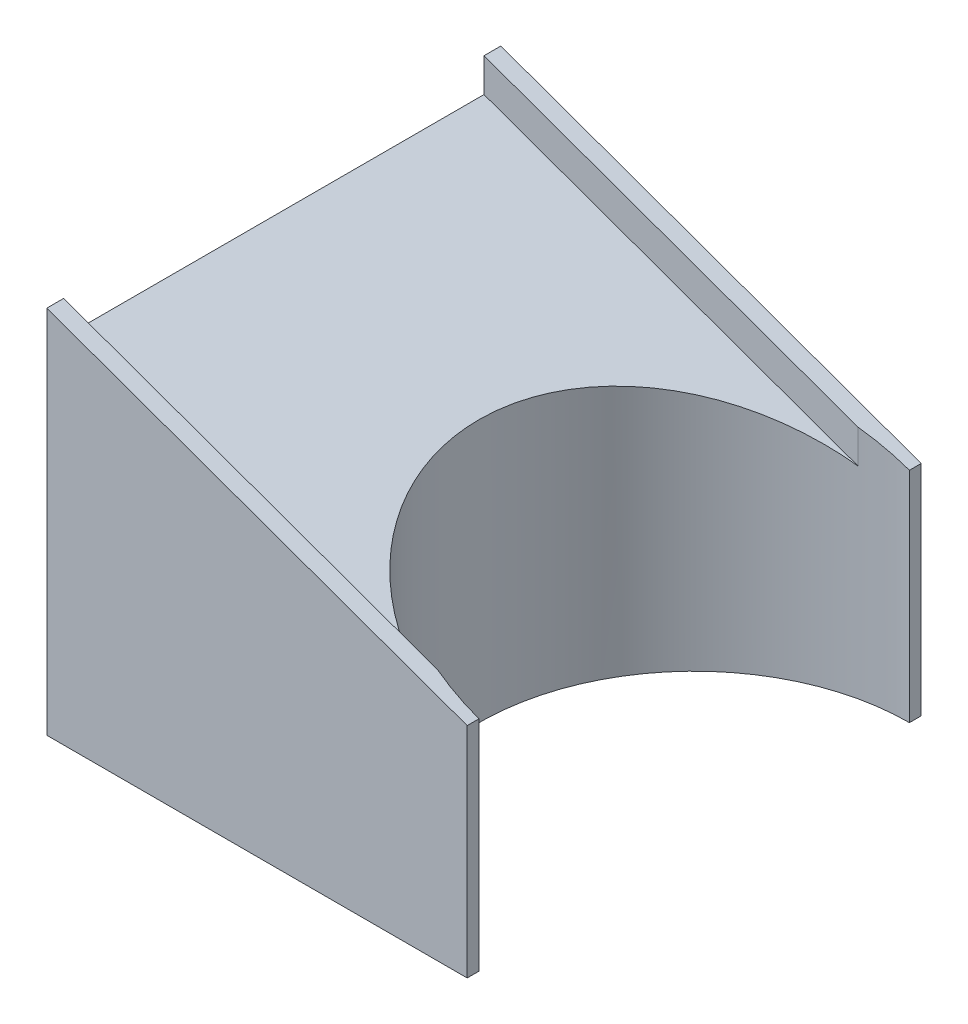
from build123d import *

# Parameters (mm, degrees)
BOSS_EXTRUDE1_DEPTH        = 62.5
BOSS_EXTRUDE2_DEPTH        = 5
SKETCH3_R                  = 64
CUT_EXTRUDE1_DEPTH         = 111
F_10_CLEARANCE_HOLE1_D     = 4.7752
F_10_CLEARANCE_HOLE1_DEPTH = 12.7
F_10_CLEARANCE_HOLE1_TIP   = 1.434614814


with BuildPart() as part:
    # Sketch2 → Boss-Extrude1 (new body, symmetric)
    with BuildSketch(Plane.XY):
        Polygon((0, 0), (0, 100), (125, 55), (125, 0), align=None)
    extrude(amount=BOSS_EXTRUDE1_DEPTH, both=True)

    # Sketch4 → Boss-Extrude2 (add)
    with BuildSketch(Plane.XY.offset(62.5)):
        Polygon((0, 0), (0, 110), (125, 65), (125, 0), align=None)
    boss_extrude2 = extrude(amount=BOSS_EXTRUDE2_DEPTH)

    # Mirror1: Boss-Extrude2 across plane
    add(boss_extrude2.mirror(Plane.XY))

    # Sketch3 → Cut-Extrude1 (cut, through all)
    with BuildSketch(Plane.XZ):
        with Locations((125, 0)):
            Circle(SKETCH3_R)
    extrude(amount=-CUT_EXTRUDE1_DEPTH, mode=Mode.SUBTRACT)

    # #10 Clearance Hole1
    with Locations(Plane.ZY):
        with Locations((0, 55), (0, 20)):
            Hole(F_10_CLEARANCE_HOLE1_D / 2, depth=F_10_CLEARANCE_HOLE1_DEPTH)
            with Locations((0, 0, -(F_10_CLEARANCE_HOLE1_DEPTH + F_10_CLEARANCE_HOLE1_TIP / 2))):  # 118° drill point
                Cone(0, F_10_CLEARANCE_HOLE1_D / 2, F_10_CLEARANCE_HOLE1_TIP, mode=Mode.SUBTRACT)


solid = part.part
